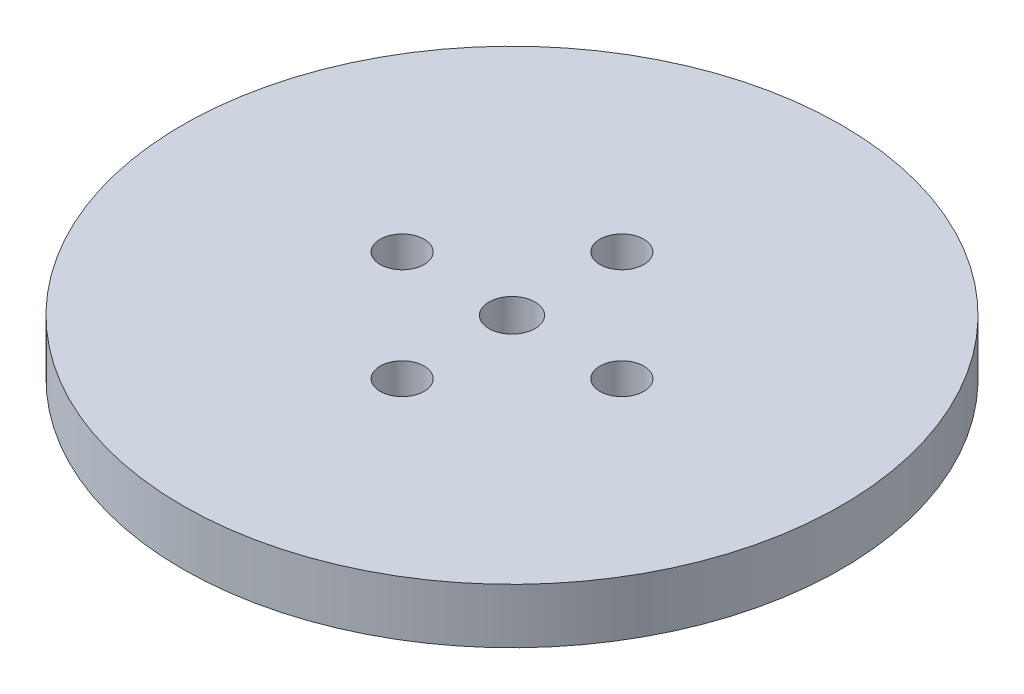
from build123d import *

# Parameters (mm, degrees)
CROQUIS1_R              = 2.05
CROQUIS1_R_2            = 4
SALIENTE_EXTRUIR1_DEPTH = 25.4
CROQUIS2_R              = 30
SALIENTE_EXTRUIR2_DEPTH = 5
CROQUIS3_R              = 2
CORTAR_EXTRUIR1_DEPTH   = 7.5
CROQUIS7_R              = 3.5
CORTAR_EXTRUIR3_DEPTH   = 3
CROQUIS8_W              = 62.698346187
CROQUIS8_H              = 3
CORTAR_EXTRUIR5_DEPTH   = 15
CROQUIS1_3_R            = 2.05
CORTAR_EXTRUIR6_DEPTH   = 7.4
SALIENTE_EXTRUIR3_DEPTH = 10
CROQUIS6_R              = 1.25
CORTAR_EXTRUIR7_DEPTH   = 10
CROQUIS10_R             = 4.00257807
CORTAR_EXTRUIR8_DEPTH   = 20
CROQUIS11_R             = 2.1
CORTAR_EXTRUIR9_DEPTH   = 20


with BuildPart() as part:
    # Croquis1 → Saliente-Extruir1 (new body)
    with BuildSketch(Plane(origin=(0, 0, 0), x_dir=(1, 0, 0), z_dir=(0, 1, 0))):
        Circle(CROQUIS1_R)
        Circle(CROQUIS1_R_2)
        Circle(CROQUIS1_R, mode=Mode.SUBTRACT)
    extrude(amount=SALIENTE_EXTRUIR1_DEPTH)

    # Croquis2 → Saliente-Extruir2 (add)
    with BuildSketch(Plane(origin=(0, 25.4, 0), x_dir=(1, 0, 0), z_dir=(0, 1, 0))):
        Circle(CROQUIS2_R)
    extrude(amount=SALIENTE_EXTRUIR2_DEPTH)

    # Croquis3 → Cortar-Extruir1 (cut)
    with BuildSketch(Plane(origin=(0, 30.4, 0), x_dir=(1, 0, 0), z_dir=(0, 1, 0))):
        with Locations((0, 10)):
            Circle(CROQUIS3_R)
        with Locations((10, 0)):
            Circle(CROQUIS3_R)
        with Locations((0, -10)):
            Circle(CROQUIS3_R)
        with Locations((-10, 0)):
            Circle(CROQUIS3_R)
    extrude(amount=-CORTAR_EXTRUIR1_DEPTH, mode=Mode.SUBTRACT)

    # Croquis7 → Cortar-Extruir3 (cut)
    with BuildSketch(Plane.XZ):
        Circle(CROQUIS7_R)
    extrude(amount=-CORTAR_EXTRUIR3_DEPTH, mode=Mode.SUBTRACT)

    # Croquis8 → Cortar-Extruir5 (cut, symmetric)
    with BuildSketch(Plane(origin=(0, 0, 0), x_dir=(0, 0, -1), z_dir=(1, 0, 0))):
        with Locations((4.276742622, 1.5)):
            Rectangle(CROQUIS8_W, CROQUIS8_H)
    extrude(amount=CORTAR_EXTRUIR5_DEPTH, both=True, mode=Mode.SUBTRACT)

    # Croquis1_3 → Cortar-Extruir6 (cut)
    with BuildSketch(Plane(origin=(0, 0, 0), x_dir=(1, 0, 0), z_dir=(0, 1, 0))):
        Circle(CROQUIS1_3_R)
    extrude(amount=CORTAR_EXTRUIR6_DEPTH, mode=Mode.SUBTRACT)

    # Croquis9 → Saliente-Extruir3 (add)
    with BuildSketch(Plane.XZ.offset(-3)):
        with BuildLine():
            ThreePointArc((1.281600562, 1.6), (0, 2.05), (-1.281600562, 1.6))
            Line((-1.281600562, 1.6), (1.281600562, 1.6))
        make_face()
    extrude(amount=-SALIENTE_EXTRUIR3_DEPTH)

    # Croquis6 → Cortar-Extruir7 (cut)
    with BuildSketch(Plane.XY):
        with Locations((0, 5)):
            Circle(CROQUIS6_R)
    extrude(amount=CORTAR_EXTRUIR7_DEPTH, mode=Mode.SUBTRACT)

    # Croquis10 → Cortar-Extruir8 (cut)
    with BuildSketch(Plane.XZ.offset(-3)):
        Circle(CROQUIS10_R)
    extrude(amount=-CORTAR_EXTRUIR8_DEPTH, mode=Mode.SUBTRACT)

    # Croquis11 → Cortar-Extruir9 (cut)
    with BuildSketch(Plane(origin=(0, 30.4, 0), x_dir=(1, 0, 0), z_dir=(0, 1, 0))):
        Circle(CROQUIS11_R)
    extrude(amount=-CORTAR_EXTRUIR9_DEPTH, mode=Mode.SUBTRACT)


solid = part.part
